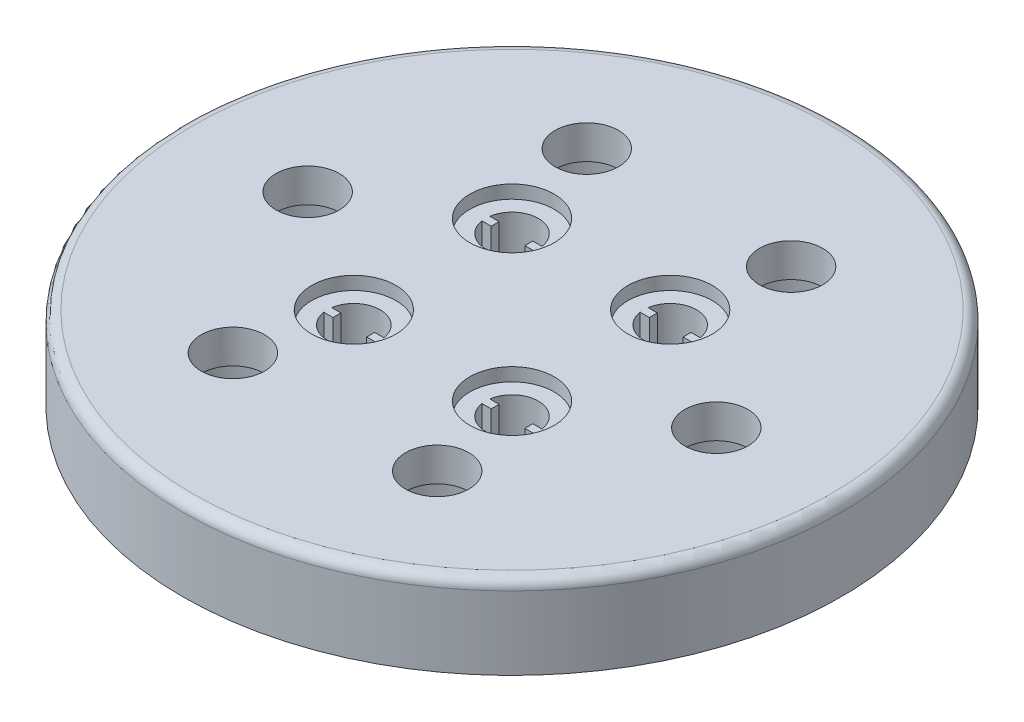
from build123d import *

# Parameters (mm, degrees)
SKETCH1_R           = 25
BOSS_EXTRUDE1_DEPTH = 6.35
SKETCH3_R           = 2.4
CUT_EXTRUDE3_DEPTH  = 7.35
SKETCH4_R           = 4.65
CUT_EXTRUDE4_DEPTH  = 3.8
CIRPATTERN3_COUNT   = 6
SKETCH5_R           = 1.25
CUT_EXTRUDE5_DEPTH  = 7.35
CUT_EXTRUDE6_DEPTH  = 7.35
SKETCH8_R           = 3.2
CUT_EXTRUDE7_DEPTH  = 1
FILLET1_R           = 0.8


with BuildPart() as part:
    # Sketch1 → Boss-Extrude1 (new body)
    with BuildSketch(Plane(origin=(0, 0, 0), x_dir=(1, 0, 0), z_dir=(0, 1, 0))):
        Circle(SKETCH1_R)
    extrude(amount=BOSS_EXTRUDE1_DEPTH)

    # Sketch3 → Cut-Extrude3 (cut, through all)
    with BuildSketch(Plane.XZ):
        with Locations((-15.5, 0)):
            Circle(SKETCH3_R)
    cut_extrude3 = extrude(amount=-CUT_EXTRUDE3_DEPTH, mode=Mode.SUBTRACT)

    # Sketch4 → Cut-Extrude4 (cut)
    with BuildSketch(Plane.XZ):
        with Locations((-15.5, 0)):
            Circle(SKETCH4_R)
    cut_extrude4 = extrude(amount=-CUT_EXTRUDE4_DEPTH, mode=Mode.SUBTRACT)

    # CirPattern3: Cut-Extrude3, Cut-Extrude4 ×6 about axis
    cirpattern3_axis = Axis((0, 0, 0), (0, 1, 0))
    for i in range(1, CIRPATTERN3_COUNT):
        add(cut_extrude3.rotate(cirpattern3_axis, i * 360 / CIRPATTERN3_COUNT), mode=Mode.SUBTRACT)
        add(cut_extrude4.rotate(cirpattern3_axis, i * 360 / CIRPATTERN3_COUNT), mode=Mode.SUBTRACT)

    # Sketch5 → Cut-Extrude5 (cut, through all)
    with BuildSketch(Plane.XZ):
        with Locations((-6, -6)):
            Circle(SKETCH5_R)
        with Locations((6, -6)):
            Circle(SKETCH5_R)
        with Locations((-6, 6)):
            Circle(SKETCH5_R)
        with Locations((6, 6)):
            Circle(SKETCH5_R)
    extrude(amount=-CUT_EXTRUDE5_DEPTH, mode=Mode.SUBTRACT)

    # Sketch7 → Cut-Extrude6 (cut, through all)
    with BuildSketch(Plane(origin=(0, 6.35, 0), x_dir=(1, 0, 0), z_dir=(0, 1, 0))):
        with BuildLine():
            Line((4.022628007, 6.3), (4.722628007, 6.3))
            Line((4.722628007, 6.3), (4.722628007, 5.7))
            Line((4.722628007, 5.7), (4.022628007, 5.7))
            ThreePointArc((4.022628007, 5.7), (6, 4), (7.977371993, 5.7))
            Line((7.977371993, 5.7), (7.277371993, 5.7))
            Line((7.277371993, 5.7), (7.277371993, 6.3))
            Line((7.277371993, 6.3), (7.977371993, 6.3))
            ThreePointArc((7.977371993, 6.3), (6, 8), (4.022628007, 6.3))
        make_face()
        with BuildLine():
            Line((-7.277371993, 6.3), (-7.277371993, 5.7))
            Line((-7.277371993, 5.7), (-7.977371993, 5.7))
            ThreePointArc((-7.977371993, 5.7), (-6, 4), (-4.022628007, 5.7))
            Line((-4.022628007, 5.7), (-4.722628007, 5.7))
            Line((-4.722628007, 5.7), (-4.722628007, 6.3))
            Line((-4.722628007, 6.3), (-4.022628007, 6.3))
            ThreePointArc((-4.022628007, 6.3), (-6, 8), (-7.977371993, 6.3))
            Line((-7.977371993, 6.3), (-7.277371993, 6.3))
        make_face()
        with BuildLine():
            Line((-4.022628007, -6.3), (-4.722628007, -6.3))
            Line((-4.722628007, -6.3), (-4.722628007, -5.7))
            Line((-4.722628007, -5.7), (-4.022628007, -5.7))
            ThreePointArc((-4.022628007, -5.7), (-6, -4), (-7.977371993, -5.7))
            Line((-7.977371993, -5.7), (-7.277371993, -5.7))
            Line((-7.277371993, -5.7), (-7.277371993, -6.3))
            Line((-7.277371993, -6.3), (-7.977371993, -6.3))
            ThreePointArc((-7.977371993, -6.3), (-6, -8), (-4.022628007, -6.3))
        make_face()
        with BuildLine():
            Line((7.277371993, -6.3), (7.277371993, -5.7))
            Line((7.277371993, -5.7), (7.977371993, -5.7))
            ThreePointArc((7.977371993, -5.7), (6, -4), (4.022628007, -5.7))
            Line((4.022628007, -5.7), (4.722628007, -5.7))
            Line((4.722628007, -5.7), (4.722628007, -6.3))
            Line((4.722628007, -6.3), (4.022628007, -6.3))
            ThreePointArc((4.022628007, -6.3), (6, -8), (7.977371993, -6.3))
            Line((7.977371993, -6.3), (7.277371993, -6.3))
        make_face()
    extrude(amount=-CUT_EXTRUDE6_DEPTH, mode=Mode.SUBTRACT)

    # Sketch8 → Cut-Extrude7 (cut)
    with BuildSketch(Plane(origin=(0, 6.35, 0), x_dir=(1, 0, 0), z_dir=(0, 1, 0))):
        with Locations((6, -6)):
            Circle(SKETCH8_R)
        with Locations((6, 6)):
            Circle(SKETCH8_R)
        with Locations((-6, 6)):
            Circle(SKETCH8_R)
        with Locations((-6, -6)):
            Circle(SKETCH8_R)
    extrude(amount=-CUT_EXTRUDE7_DEPTH, mode=Mode.SUBTRACT)

    # Fillet1
    fillet1_edges = [part.edges().sort_by_distance(p)[0] for p in [
        (-25, 6.35, 0),
    ]]
    fillet(fillet1_edges, radius=FILLET1_R)


solid = part.part
